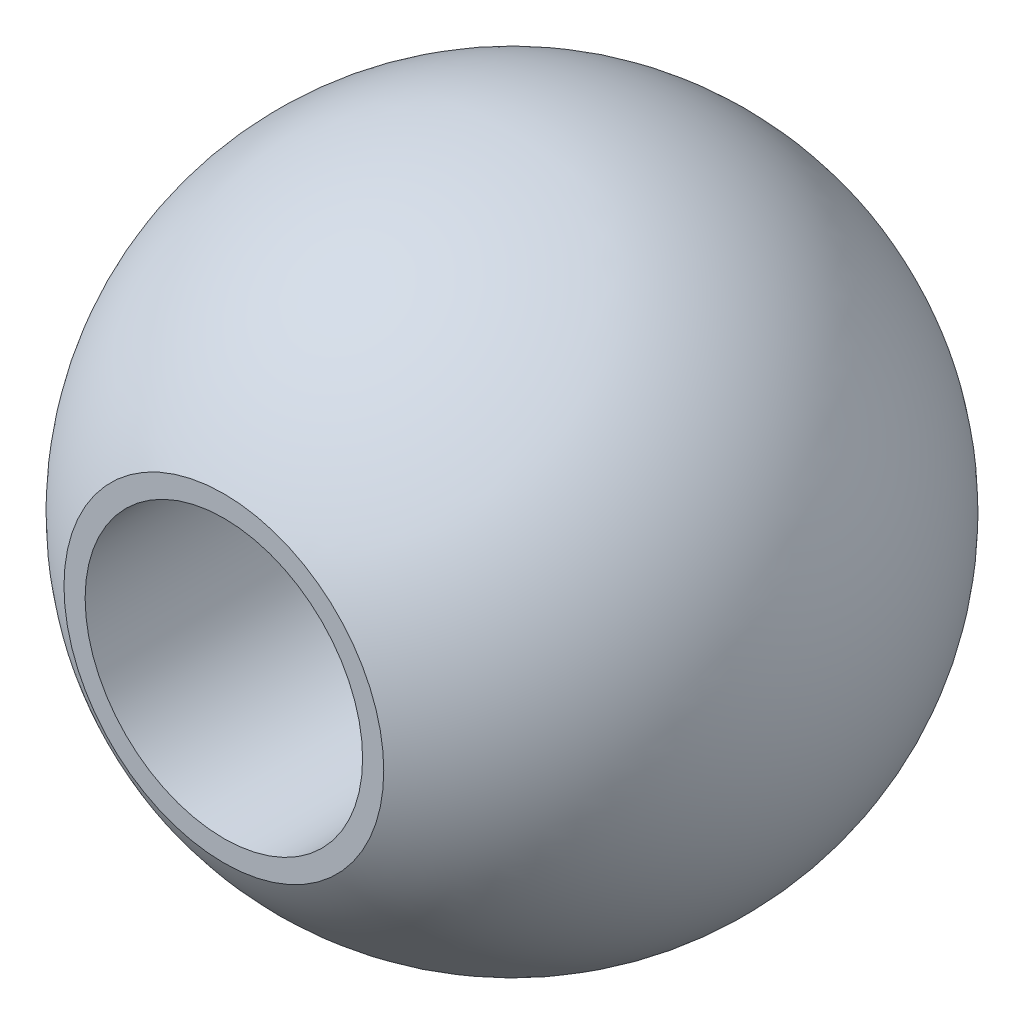
from build123d import *

# Parameters (mm, degrees)
SKETCH2_R               = 4
CUT_EXTRUDE1_DEPTH      = 10.5
CUT_EXTRUDE1_DEPTH_BACK = 10.5
CUT_EXTRUDE2_DEPTH      = 10.5
CUT_EXTRUDE2_DEPTH_BACK = 10.5


with BuildPart() as part:
    # Sketch1 → Revolve1 (revolve)
    with BuildSketch(Plane.XY):
        with BuildLine():
            Line((0, 0), (0, 9.5))
            ThreePointArc((0, 9.5), (-9.5, 0), (0, -9.5))
            Line((0, -9.5), (0, 0))
        make_face()
    revolve(axis=Axis((0, 0, 0), (0, 1, 0)))

    # Sketch2 → Cut-Extrude1 (cut, two sides)
    with BuildSketch(Plane.XY) as cut_extrude1_sk:
        Circle(SKETCH2_R)
    extrude(amount=CUT_EXTRUDE1_DEPTH, mode=Mode.SUBTRACT)
    extrude(cut_extrude1_sk.sketch, amount=-CUT_EXTRUDE1_DEPTH_BACK, mode=Mode.SUBTRACT)

    # Sketch3 → Cut-Extrude2 (cut, two sides)
    with BuildSketch(Plane(origin=(0, 0, 0), x_dir=(0, 0, -1), z_dir=(1, 0, 0))) as cut_extrude2_sk:
        Polygon((-8.306544706, 4.609914863), (-8.306544706, -4.609914863), (-10.633292183, -4.98233366), (-10.309764023, 4.831353852), align=None)
        Polygon((8.306544706, 4.609914863), (8.306544706, -4.609914863), (13.199948917, -3.386261405), (13.199948917, 5.629389979), align=None)
    extrude(amount=CUT_EXTRUDE2_DEPTH, mode=Mode.SUBTRACT)
    extrude(cut_extrude2_sk.sketch, amount=-CUT_EXTRUDE2_DEPTH_BACK, mode=Mode.SUBTRACT)


solid = part.part
